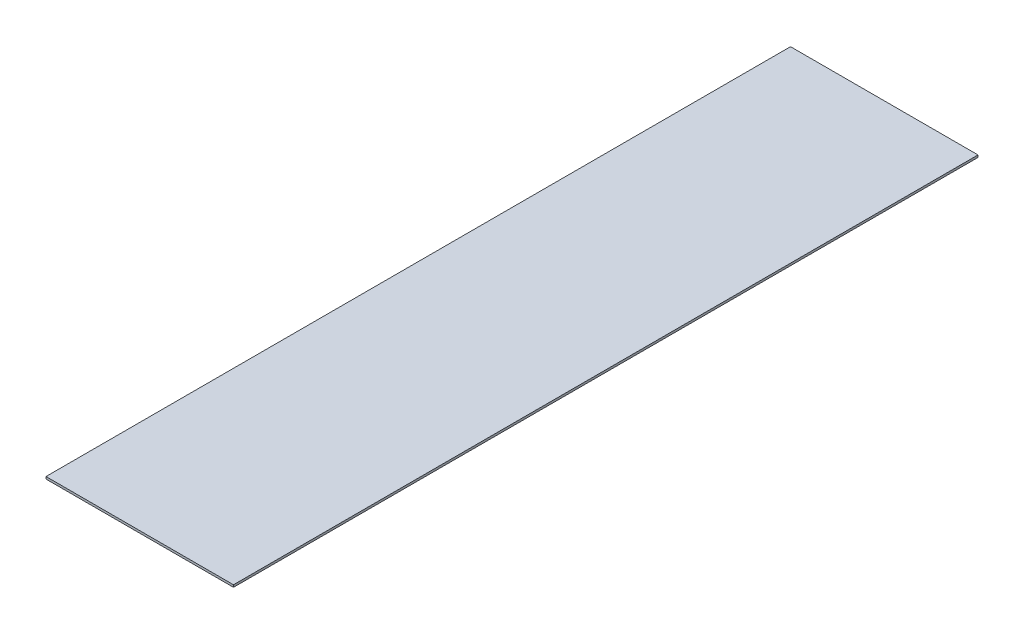
from build123d import *

# Parameters (mm, degrees)
SKETCH2_W           = 4194.120001994
SKETCH2_H           = 16654.853484584
BOSS_EXTRUDE1_DEPTH = 50


with BuildPart() as part:
    # Sketch2 → Boss-Extrude1 (new body)
    with BuildSketch(Plane(origin=(0, 0, 0), x_dir=(1, 0, 0), z_dir=(0, 1, 0))):
        with Locations((0, 5599.904487956)):
            Rectangle(SKETCH2_W, SKETCH2_H)
    extrude(amount=-BOSS_EXTRUDE1_DEPTH)


solid = part.part
